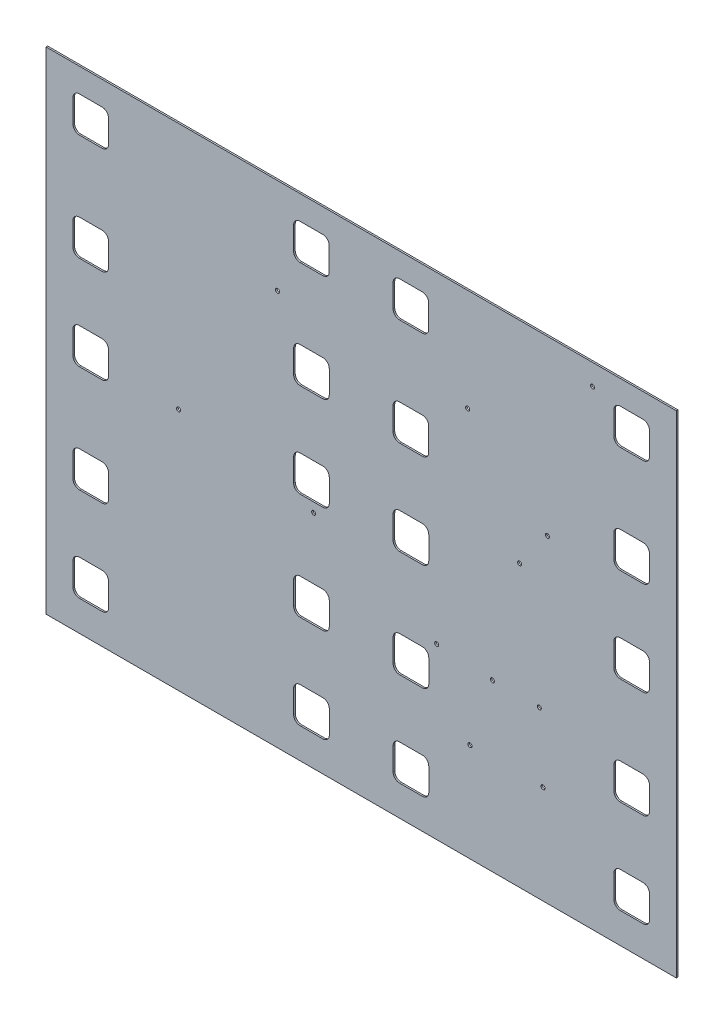
from build123d import *

# Parameters (mm, degrees)
BOSS_EXTRUDE2_DEPTH  = 1.5875
CUT_EXTRUDE6_DEPTH   = 2.5875
LPATTERN2_COUNT      = 2
LPATTERN2_PITCH      = 217.5764
MIRROR1_COPY_1_DEPTH = 2.5875
SKETCH11_R           = 1.9939
CUT_EXTRUDE7_DEPTH   = 2.5875


with BuildPart() as part:
    # Sketch9 → Boss-Extrude2 (new body)
    with BuildSketch(Plane.XY):
        Polygon((-144.375457148, 172.737459045), (-144.32459706, -311.513538284), (476.933999514, -311.448288512), (476.883139425, 172.802708817), align=None)
        with BuildLine():
            ThreePointArc((-82.74856916, -252.74427073), (-84.60891268, -248.254338034), (-89.099236055, -246.394937696))
            Line((-89.099236055, -246.394937696), (-111.527235931, -246.397293272))
            ThreePointArc((-111.527235931, -246.397293272), (-116.017168628, -248.257636792), (-117.876568966, -252.747960167))
            Line((-117.876568966, -252.747960167), (-117.87421339, -275.175960043))
            ThreePointArc((-117.87421339, -275.175960043), (-116.01386987, -279.665892739), (-111.523546495, -281.525293078))
            Line((-111.523546495, -281.525293078), (-89.095546619, -281.522937502))
            ThreePointArc((-89.095546619, -281.522937502), (-84.605613922, -279.662593982), (-82.746213584, -275.172270607))
            Line((-82.746213584, -275.172270607), (-82.74856916, -252.74427073))
        make_face(mode=Mode.SUBTRACT)
        with BuildLine():
            ThreePointArc((-111.557725307, 43.899305127), (-116.047658003, 42.038961607), (-117.907058342, 37.548638232))
            Line((-117.907058342, 37.548638232), (-117.904702766, 15.120638356))
            ThreePointArc((-117.904702766, 15.120638356), (-116.044359246, 10.630705659), (-111.554035871, 8.771305321))
            Line((-111.554035871, 8.771305321), (-89.126035994, 8.773660897))
            ThreePointArc((-89.126035994, 8.773660897), (-84.636103298, 10.634004417), (-82.77670296, 15.124327792))
            Line((-82.77670296, 15.124327792), (-82.779058536, 37.552327668))
            ThreePointArc((-82.779058536, 37.552327668), (-84.639402056, 42.042260365), (-89.129725431, 43.901660703))
            Line((-89.129725431, 43.901660703), (-111.557725307, 43.899305127))
        make_face(mode=Mode.SUBTRACT)
        with BuildLine():
            ThreePointArc((-117.91574446, 120.251237776), (-116.05540094, 115.76130508), (-111.565077565, 113.901904741))
            Line((-111.565077565, 113.901904741), (-89.137077689, 113.904260317))
            ThreePointArc((-89.137077689, 113.904260317), (-84.647144992, 115.764603837), (-82.787744654, 120.254927212))
            Line((-82.787744654, 120.254927212), (-82.79010023, 142.682927089))
            ThreePointArc((-82.79010023, 142.682927089), (-84.65044375, 147.172859785), (-89.140767125, 149.032260123))
            Line((-89.140767125, 149.032260123), (-111.568767001, 149.029904547))
            ThreePointArc((-111.568767001, 149.029904547), (-116.058699698, 147.169561027), (-117.918100036, 142.679237652))
            Line((-117.918100036, 142.679237652), (-117.91574446, 120.251237776))
        make_face(mode=Mode.SUBTRACT)
        with BuildLine():
            ThreePointArc((-117.894978925, -77.462361134), (-116.034635405, -81.95229383), (-111.54431203, -83.811694168))
            Line((-111.54431203, -83.811694168), (-89.116312154, -83.809338592))
            ThreePointArc((-89.116312154, -83.809338592), (-84.626379457, -81.948995072), (-82.766979119, -77.458671697))
            Line((-82.766979119, -77.458671697), (-82.769334695, -55.030671821))
            ThreePointArc((-82.769334695, -55.030671821), (-84.629678215, -50.540739125), (-89.12000159, -48.681338786))
            Line((-89.12000159, -48.681338786), (-111.548001466, -48.683694362))
            ThreePointArc((-111.548001466, -48.683694362), (-116.037934163, -50.544037882), (-117.897334501, -55.034361257))
            Line((-117.897334501, -55.034361257), (-117.894978925, -77.462361134))
        make_face(mode=Mode.SUBTRACT)
        with BuildLine():
            ThreePointArc((-117.883937231, -182.592960554), (-116.023593711, -187.08289325), (-111.533270336, -188.942293589))
            Line((-111.533270336, -188.942293589), (-89.105270459, -188.939938013))
            ThreePointArc((-89.105270459, -188.939938013), (-84.615337763, -187.079594493), (-82.755937424, -182.589271117))
            Line((-82.755937424, -182.589271117), (-82.758293, -160.161271241))
            ThreePointArc((-82.758293, -160.161271241), (-84.61863652, -155.671338545), (-89.108959895, -153.811938206))
            Line((-89.108959895, -153.811938206), (-111.536959772, -153.814293782))
            ThreePointArc((-111.536959772, -153.814293782), (-116.026892468, -155.674637302), (-117.886292807, -160.164960677))
            Line((-117.886292807, -160.164960677), (-117.883937231, -182.592960554))
        make_face(mode=Mode.SUBTRACT)
        with BuildLine():
            Line((-82.746213584, -275.172270607), (-82.74856916, -252.74427073))
            ThreePointArc((-82.74856916, -252.74427073), (-84.60891268, -248.254338034), (-89.099236055, -246.394937696))
            Line((-89.099236055, -246.394937696), (-111.527235931, -246.397293272))
            ThreePointArc((-111.527235931, -246.397293272), (-116.017168628, -248.257636792), (-117.876568966, -252.747960167))
            Line((-117.876568966, -252.747960167), (-117.87421339, -275.175960043))
            ThreePointArc((-117.87421339, -275.175960043), (-116.01386987, -279.665892739), (-111.523546495, -281.525293078))
            Line((-111.523546495, -281.525293078), (-89.095546619, -281.522937502))
            ThreePointArc((-89.095546619, -281.522937502), (-84.605613922, -279.662593982), (-82.746213584, -275.172270607))
        make_face()
        with BuildLine():
            Line((-117.886292807, -160.164960677), (-117.883937231, -182.592960554))
            ThreePointArc((-117.883937231, -182.592960554), (-116.023593711, -187.08289325), (-111.533270336, -188.942293589))
            Line((-111.533270336, -188.942293589), (-89.105270459, -188.939938013))
            ThreePointArc((-89.105270459, -188.939938013), (-84.615337763, -187.079594493), (-82.755937424, -182.589271117))
            Line((-82.755937424, -182.589271117), (-82.758293, -160.161271241))
            ThreePointArc((-82.758293, -160.161271241), (-84.61863652, -155.671338545), (-89.108959895, -153.811938206))
            Line((-89.108959895, -153.811938206), (-111.536959772, -153.814293782))
            ThreePointArc((-111.536959772, -153.814293782), (-116.026892468, -155.674637302), (-117.886292807, -160.164960677))
        make_face()
        with BuildLine():
            Line((-89.129725431, 43.901660703), (-111.557725307, 43.899305127))
            ThreePointArc((-111.557725307, 43.899305127), (-116.047658003, 42.038961607), (-117.907058342, 37.548638232))
            Line((-117.907058342, 37.548638232), (-117.904702766, 15.120638356))
            ThreePointArc((-117.904702766, 15.120638356), (-116.044359246, 10.630705659), (-111.554035871, 8.771305321))
            Line((-111.554035871, 8.771305321), (-89.126035994, 8.773660897))
            ThreePointArc((-89.126035994, 8.773660897), (-84.636103298, 10.634004417), (-82.77670296, 15.124327792))
            Line((-82.77670296, 15.124327792), (-82.779058536, 37.552327668))
            ThreePointArc((-82.779058536, 37.552327668), (-84.639402056, 42.042260365), (-89.129725431, 43.901660703))
        make_face()
        with BuildLine():
            Line((-117.918100036, 142.679237652), (-117.91574446, 120.251237776))
            ThreePointArc((-117.91574446, 120.251237776), (-116.05540094, 115.76130508), (-111.565077565, 113.901904741))
            Line((-111.565077565, 113.901904741), (-89.137077689, 113.904260317))
            ThreePointArc((-89.137077689, 113.904260317), (-84.647144992, 115.764603837), (-82.787744654, 120.254927212))
            Line((-82.787744654, 120.254927212), (-82.79010023, 142.682927089))
            ThreePointArc((-82.79010023, 142.682927089), (-84.65044375, 147.172859785), (-89.140767125, 149.032260123))
            Line((-89.140767125, 149.032260123), (-111.568767001, 149.029904547))
            ThreePointArc((-111.568767001, 149.029904547), (-116.058699698, 147.169561027), (-117.918100036, 142.679237652))
        make_face()
        with BuildLine():
            Line((-117.897334501, -55.034361257), (-117.894978925, -77.462361134))
            ThreePointArc((-117.894978925, -77.462361134), (-116.034635405, -81.95229383), (-111.54431203, -83.811694168))
            Line((-111.54431203, -83.811694168), (-89.116312154, -83.809338592))
            ThreePointArc((-89.116312154, -83.809338592), (-84.626379457, -81.948995072), (-82.766979119, -77.458671697))
            Line((-82.766979119, -77.458671697), (-82.769334695, -55.030671821))
            ThreePointArc((-82.769334695, -55.030671821), (-84.629678215, -50.540739125), (-89.12000159, -48.681338786))
            Line((-89.12000159, -48.681338786), (-111.548001466, -48.683694362))
            ThreePointArc((-111.548001466, -48.683694362), (-116.037934163, -50.544037882), (-117.897334501, -55.034361257))
        make_face()
    extrude(amount=BOSS_EXTRUDE2_DEPTH)

    # Sketch10 → Cut-Extrude6 (cut, through all)
    with BuildSketch(Plane.XY.offset(1.5875)):
        with BuildLine():
            Line((-82.787744654, 120.254927212), (-82.79010023, 142.682927089))
            ThreePointArc((-82.79010023, 142.682927089), (-84.65044375, 147.172859785), (-89.140767125, 149.032260123))
            Line((-89.140767125, 149.032260123), (-111.568767001, 149.029904547))
            ThreePointArc((-111.568767001, 149.029904547), (-116.058699698, 147.169561027), (-117.918100036, 142.679237652))
            Line((-117.918100036, 142.679237652), (-117.91574446, 120.251237776))
            ThreePointArc((-117.91574446, 120.251237776), (-116.05540094, 115.76130508), (-111.565077565, 113.901904741))
            Line((-111.565077565, 113.901904741), (-89.137077689, 113.904260317))
            ThreePointArc((-89.137077689, 113.904260317), (-84.647144992, 115.764603837), (-82.787744654, 120.254927212))
        make_face()
        with BuildLine():
            Line((-117.907058342, 37.548638232), (-117.904702766, 15.120638356))
            ThreePointArc((-117.904702766, 15.120638356), (-116.044359246, 10.630705659), (-111.554035871, 8.771305321))
            Line((-111.554035871, 8.771305321), (-89.126035994, 8.773660897))
            ThreePointArc((-89.126035994, 8.773660897), (-84.636103298, 10.634004417), (-82.77670296, 15.124327792))
            Line((-82.77670296, 15.124327792), (-82.779058536, 37.552327668))
            ThreePointArc((-82.779058536, 37.552327668), (-84.639402056, 42.042260365), (-89.129725431, 43.901660703))
            Line((-89.129725431, 43.901660703), (-111.557725307, 43.899305127))
            ThreePointArc((-111.557725307, 43.899305127), (-116.047658003, 42.038961607), (-117.907058342, 37.548638232))
        make_face()
        with BuildLine():
            Line((-82.766979119, -77.458671697), (-82.769334695, -55.030671821))
            ThreePointArc((-82.769334695, -55.030671821), (-84.629678215, -50.540739125), (-89.12000159, -48.681338786))
            Line((-89.12000159, -48.681338786), (-111.548001466, -48.683694362))
            ThreePointArc((-111.548001466, -48.683694362), (-116.037934163, -50.544037882), (-117.897334501, -55.034361257))
            Line((-117.897334501, -55.034361257), (-117.894978925, -77.462361134))
            ThreePointArc((-117.894978925, -77.462361134), (-116.034635405, -81.95229383), (-111.54431203, -83.811694168))
            Line((-111.54431203, -83.811694168), (-89.116312154, -83.809338592))
            ThreePointArc((-89.116312154, -83.809338592), (-84.626379457, -81.948995072), (-82.766979119, -77.458671697))
        make_face()
        with BuildLine():
            Line((-89.108959895, -153.811938206), (-111.536959772, -153.814293782))
            ThreePointArc((-111.536959772, -153.814293782), (-116.026892468, -155.674637302), (-117.886292807, -160.164960677))
            Line((-117.886292807, -160.164960677), (-117.883937231, -182.592960554))
            ThreePointArc((-117.883937231, -182.592960554), (-116.023593711, -187.08289325), (-111.533270336, -188.942293589))
            Line((-111.533270336, -188.942293589), (-89.105270459, -188.939938013))
            ThreePointArc((-89.105270459, -188.939938013), (-84.615337763, -187.079594493), (-82.755937424, -182.589271117))
            Line((-82.755937424, -182.589271117), (-82.758293, -160.161271241))
            ThreePointArc((-82.758293, -160.161271241), (-84.61863652, -155.671338545), (-89.108959895, -153.811938206))
        make_face()
        with BuildLine():
            Line((-117.876568966, -252.747960167), (-117.87421339, -275.175960043))
            ThreePointArc((-117.87421339, -275.175960043), (-116.01386987, -279.665892739), (-111.523546495, -281.525293078))
            Line((-111.523546495, -281.525293078), (-89.095546619, -281.522937502))
            ThreePointArc((-89.095546619, -281.522937502), (-84.605613922, -279.662593982), (-82.746213584, -275.172270607))
            Line((-82.746213584, -275.172270607), (-82.74856916, -252.74427073))
            ThreePointArc((-82.74856916, -252.74427073), (-84.60891268, -248.254338034), (-89.099236055, -246.394937696))
            Line((-89.099236055, -246.394937696), (-111.527235931, -246.397293272))
            ThreePointArc((-111.527235931, -246.397293272), (-116.017168628, -248.257636792), (-117.876568966, -252.747960167))
        make_face()
    cut_extrude6 = extrude(amount=-CUT_EXTRUDE6_DEPTH, mode=Mode.SUBTRACT)

    # LPattern2: Cut-Extrude6 ×2
    with Locations(*[Vector(0.999999994, 0.000105028, 0) * (i * LPATTERN2_PITCH) for i in range(1, LPATTERN2_COUNT)]):
        add(cut_extrude6, mode=Mode.SUBTRACT)

    # Mirror1: Cut-Extrude6 across plane
    add(cut_extrude6.mirror(Plane(origin=(166.271985063, 0.017463274, 0), x_dir=(0, 0, 1), z_dir=(-0.999999994, -0.000105028, 0))), mode=Mode.SUBTRACT)

    # Mirror1 copy 1 sketch → Mirror1 copy 1 (cut, through all)
    with BuildSketch(Plane(origin=(114.967571327, 0.012074856, 1.5875), x_dir=(-0.999999978, -0.000210057, 0), z_dir=(0, 0, 1))):
        with BuildLine():
            Line((-82.787744654, -120.254927212), (-82.79010023, -142.682927089))
            ThreePointArc((-82.79010023, -142.682927089), (-84.65044375, -147.172859785), (-89.140767125, -149.032260123))
            Line((-89.140767125, -149.032260123), (-111.568767001, -149.029904547))
            ThreePointArc((-111.568767001, -149.029904547), (-116.058699698, -147.169561027), (-117.918100036, -142.679237652))
            Line((-117.918100036, -142.679237652), (-117.91574446, -120.251237776))
            ThreePointArc((-117.91574446, -120.251237776), (-116.05540094, -115.76130508), (-111.565077565, -113.901904741))
            Line((-111.565077565, -113.901904741), (-89.137077689, -113.904260317))
            ThreePointArc((-89.137077689, -113.904260317), (-84.647144992, -115.764603837), (-82.787744654, -120.254927212))
        make_face()
        with BuildLine():
            Line((-117.907058342, -37.548638232), (-117.904702766, -15.120638356))
            ThreePointArc((-117.904702766, -15.120638356), (-116.044359246, -10.630705659), (-111.554035871, -8.771305321))
            Line((-111.554035871, -8.771305321), (-89.126035994, -8.773660897))
            ThreePointArc((-89.126035994, -8.773660897), (-84.636103298, -10.634004417), (-82.77670296, -15.124327792))
            Line((-82.77670296, -15.124327792), (-82.779058536, -37.552327668))
            ThreePointArc((-82.779058536, -37.552327668), (-84.639402056, -42.042260365), (-89.129725431, -43.901660703))
            Line((-89.129725431, -43.901660703), (-111.557725307, -43.899305127))
            ThreePointArc((-111.557725307, -43.899305127), (-116.047658003, -42.038961607), (-117.907058342, -37.548638232))
        make_face()
        with BuildLine():
            Line((-82.766979119, 77.458671697), (-82.769334695, 55.030671821))
            ThreePointArc((-82.769334695, 55.030671821), (-84.629678215, 50.540739125), (-89.12000159, 48.681338786))
            Line((-89.12000159, 48.681338786), (-111.548001466, 48.683694362))
            ThreePointArc((-111.548001466, 48.683694362), (-116.037934163, 50.544037882), (-117.897334501, 55.034361257))
            Line((-117.897334501, 55.034361257), (-117.894978925, 77.462361134))
            ThreePointArc((-117.894978925, 77.462361134), (-116.034635405, 81.95229383), (-111.54431203, 83.811694168))
            Line((-111.54431203, 83.811694168), (-89.116312154, 83.809338592))
            ThreePointArc((-89.116312154, 83.809338592), (-84.626379457, 81.948995072), (-82.766979119, 77.458671697))
        make_face()
        with BuildLine():
            Line((-89.108959895, 153.811938206), (-111.536959772, 153.814293782))
            ThreePointArc((-111.536959772, 153.814293782), (-116.026892468, 155.674637302), (-117.886292807, 160.164960677))
            Line((-117.886292807, 160.164960677), (-117.883937231, 182.592960554))
            ThreePointArc((-117.883937231, 182.592960554), (-116.023593711, 187.08289325), (-111.533270336, 188.942293589))
            Line((-111.533270336, 188.942293589), (-89.105270459, 188.939938013))
            ThreePointArc((-89.105270459, 188.939938013), (-84.615337763, 187.079594493), (-82.755937424, 182.589271117))
            Line((-82.755937424, 182.589271117), (-82.758293, 160.161271241))
            ThreePointArc((-82.758293, 160.161271241), (-84.61863652, 155.671338545), (-89.108959895, 153.811938206))
        make_face()
        with BuildLine():
            Line((-117.876568966, 252.747960167), (-117.87421339, 275.175960043))
            ThreePointArc((-117.87421339, 275.175960043), (-116.01386987, 279.665892739), (-111.523546495, 281.525293078))
            Line((-111.523546495, 281.525293078), (-89.095546619, 281.522937502))
            ThreePointArc((-89.095546619, 281.522937502), (-84.605613922, 279.662593982), (-82.746213584, 275.172270607))
            Line((-82.746213584, 275.172270607), (-82.74856916, 252.74427073))
            ThreePointArc((-82.74856916, 252.74427073), (-84.60891268, 248.254338034), (-89.099236055, 246.394937696))
            Line((-89.099236055, 246.394937696), (-111.527235931, 246.397293272))
            ThreePointArc((-111.527235931, 246.397293272), (-116.017168628, 248.257636792), (-117.876568966, 252.747960167))
        make_face()
    extrude(amount=-MIRROR1_COPY_1_DEPTH, mode=Mode.SUBTRACT)

    # Sketch11 → Cut-Extrude7 (cut, through all)
    with BuildSketch(Plane.XY.offset(1.5875)):
        with Locations((295.654327064, -147.954827117)):
            Circle(SKETCH11_R)
        with Locations((394.335307404, 152.15653884)):
            Circle(SKETCH11_R)
        with Locations((271.193740547, 71.85610504)):
            Circle(SKETCH11_R)
        with Locations((83.796928701, 78.623923098)):
            Circle(SKETCH11_R)
        with Locations((-13.737316507, -71.386321592)):
            Circle(SKETCH11_R)
        with Locations((349.92453176, 2.438864357)):
            Circle(SKETCH11_R)
        with Locations((322.428430983, -34.688005186)):
            Circle(SKETCH11_R)
        with Locations((341.854326809, -147.949974807)):
            Circle(SKETCH11_R)
        with Locations((345.511300672, -214.349591087)):
            Circle(SKETCH11_R)
        with Locations((119.406061758, -93.07123788)):
            Circle(SKETCH11_R)
        with Locations((240.696463223, -144.493499232)):
            Circle(SKETCH11_R)
        with Locations((273.511301069, -214.357153129)):
            Circle(SKETCH11_R)
    extrude(amount=-CUT_EXTRUDE7_DEPTH, mode=Mode.SUBTRACT)


solid = part.part
